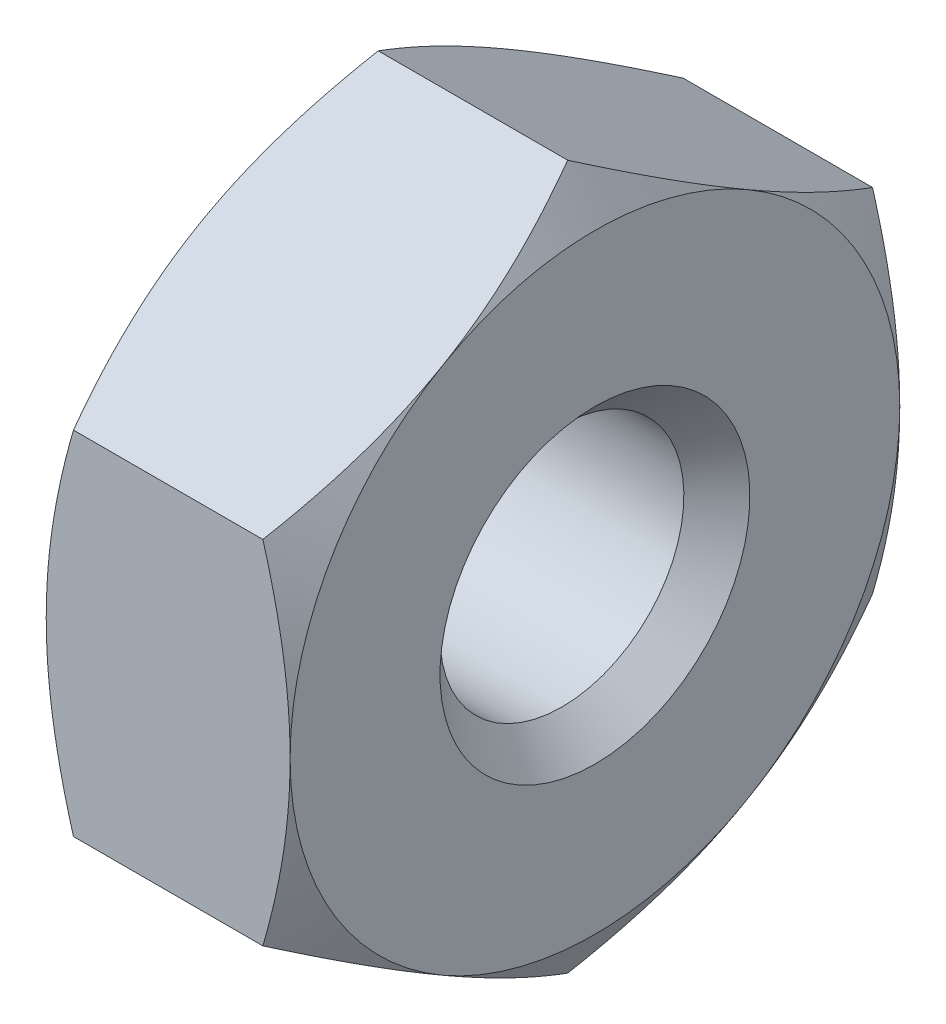
from build123d import *

# Parameters (mm, degrees)
SKETCH2_W          = 6
SKETCH2_H          = 6
CUT_EXTRUDE1_DEPTH = 1.6


with BuildPart() as part:
    # Sketch1 → Revolve1 (revolve)
    with BuildSketch(Plane.XY):
        Polygon((0, 0), (0, 2), (0.230940108, 2.4), (1.369059892, 2.4), (1.6, 2), (1.6, 0), align=None)
    revolve(axis=Axis((1.6, 0, 0), (-1, 0, 0)))

    # Sketch2 → Cut-Extrude1 (cut)
    with BuildSketch(Plane(origin=(0, 0, 0), x_dir=(0, 0, -1), z_dir=(1, 0, 0))):
        Rectangle(SKETCH2_W, SKETCH2_H)
        Polygon((-2, -1.154700538), (0, -2.309401077), (2, -1.154700538), (2, 1.154700538), (0, 2.309401077), (-2, 1.154700538), align=None, mode=Mode.SUBTRACT)
    extrude(amount=CUT_EXTRUDE1_DEPTH, mode=Mode.SUBTRACT)

    # Sketch3 → Cut-Revolve1 (revolve, cut)
    with BuildSketch(Plane.XY):
        Polygon((0, -0.0165), (0, 1), (0.2165, 0.7835), (1.3835, 0.7835), (1.6, 1), (1.6, -0.0165), align=None)
    revolve(axis=Axis((1.6, -0.0165, 0), (-1, 0, 0)), mode=Mode.SUBTRACT)


solid = part.part
